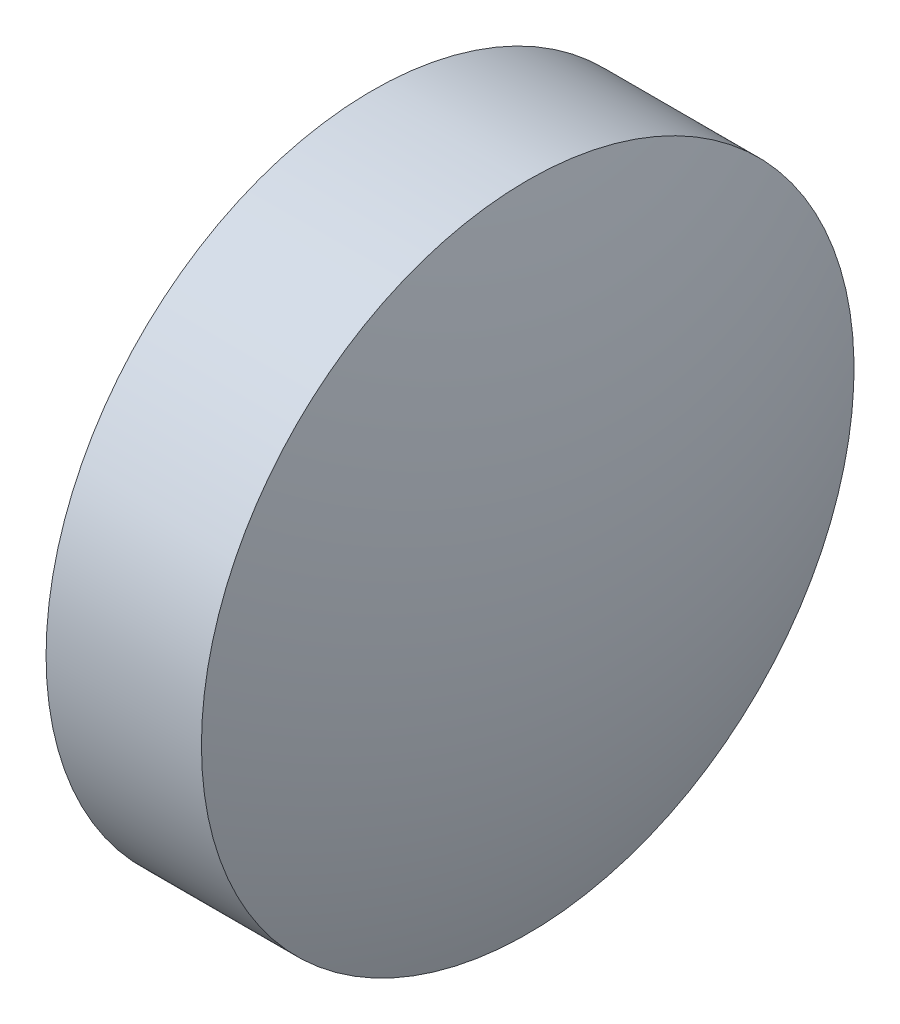
from build123d import *


with BuildPart() as part:
    # 草图1 → 旋转1 (revolve)
    with BuildSketch(Plane.XY):
        with BuildLine():
            Line((437.919836145, 10.556328338), (437.919836145, 13.706328338))
            Line((437.919836145, 13.706328338), (439.419836145, 13.706328338))
            ThreePointArc((439.419836145, 13.706328338), (439.838747115, 12.156023622), (439.979836145, 10.556328338))
            Line((439.979836145, 10.556328338), (437.919836145, 10.556328338))
        make_face()
    revolve(axis=Axis((437.059198056, 10.556328338, 0), (1, 0, 0)))


solid = part.part
